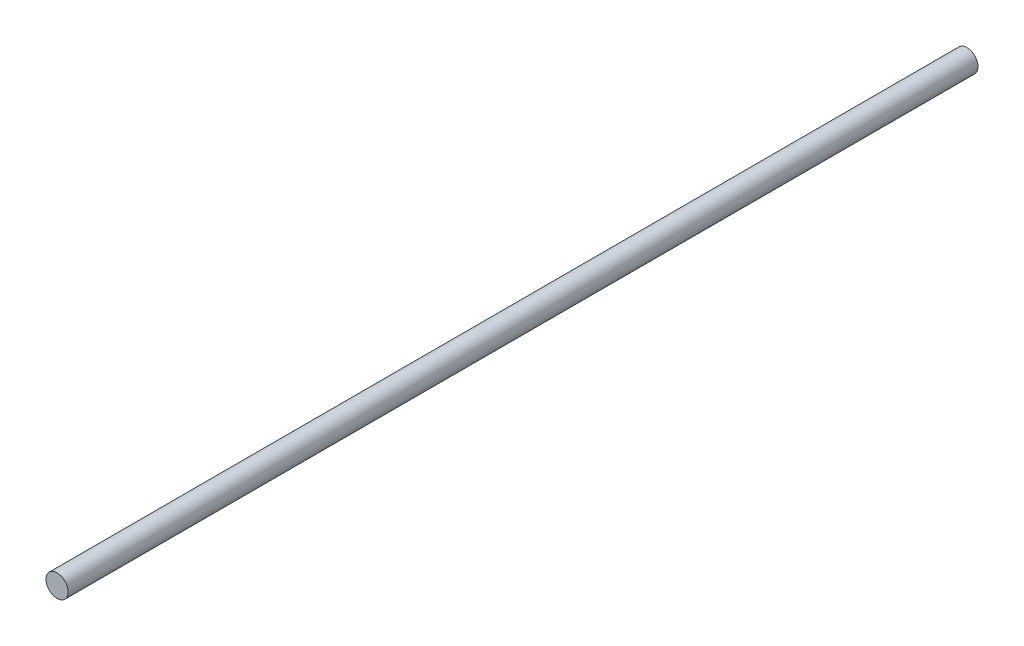
from build123d import *

# Parameters (mm, degrees)
EXTRUDE1_DEPTH      = 123
EXTRUDE1_DEPTH_BACK = 123
SKETCH1_R           = 3


with BuildPart() as part:
    # Sketch1 → Extrude1 (new, two sides: drawn at the far end of the back side and taken through both)
    with BuildSketch(Plane.XY.offset(-EXTRUDE1_DEPTH_BACK)):
        Circle(SKETCH1_R)
    extrude(amount=EXTRUDE1_DEPTH + EXTRUDE1_DEPTH_BACK)


solid = part.part
